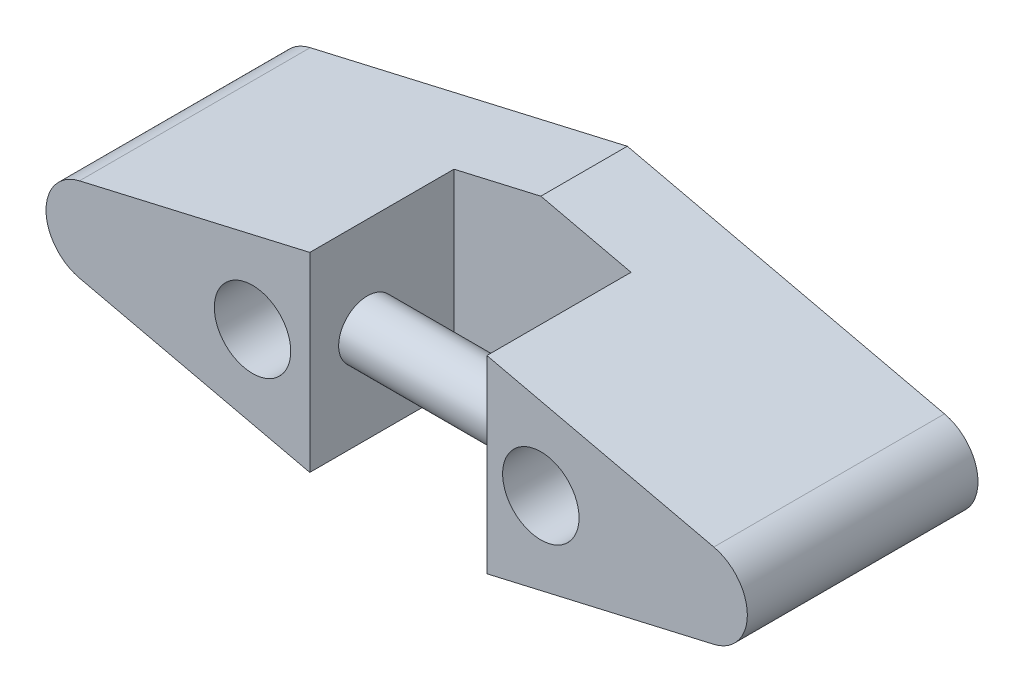
from build123d import *

# Parameters (mm, degrees)
SKETCH1_R           = 2.65
BOSS_EXTRUDE1_DEPTH = 16
SKETCH3_W           = 12.283798513
SKETCH3_H           = 21.086734885
CUT_EXTRUDE2_DEPTH  = 10
BOSS_EXTRUDE2_REACH = 32.583
SKETCH4_R           = 2


with BuildPart() as part:
    # Sketch1 → Boss-Extrude1 (new body)
    with BuildSketch(Plane.XY):
        with BuildLine():
            Line((0, 8), (-22, 2.922544759))
            ThreePointArc((-22, 2.922544759), (-24.325354345, -0.000692743), (-21.999845251, -2.923807139))
            Line((-21.999845251, -2.923807139), (0, -8))
            Line((0, -8), (21.999845251, -2.923807139))
            ThreePointArc((21.999845251, -2.923807139), (24.325354345, -0.000692743), (22, 2.922544759))
            Line((22, 2.922544759), (0, 8))
        make_face()
        with Locations((10, 0)):
            Circle(SKETCH1_R, mode=Mode.SUBTRACT)
        with Locations((-10, 0)):
            Circle(SKETCH1_R, mode=Mode.SUBTRACT)
    extrude(amount=BOSS_EXTRUDE1_DEPTH)

    # Sketch3 → Cut-Extrude2 (cut)
    with BuildSketch(Plane.XY.offset(16)):
        with Locations((0.115880044, 2.543367443)):
            Rectangle(SKETCH3_W, SKETCH3_H)
    extrude(amount=-CUT_EXTRUDE2_DEPTH, mode=Mode.SUBTRACT)

    # Sketch4 → Boss-Extrude2 (add, up to next)
    with BuildSketch(Plane.ZY.offset(-6.257779301), mode=Mode.PRIVATE) as boss_extrude2_sk1:
        with Locations((12, 0.000745713)):
            Circle(SKETCH4_R)
    boss_extrude2_tool1 = extrude(boss_extrude2_sk1.sketch, amount=BOSS_EXTRUDE2_REACH, mode=Mode.PRIVATE) - part.part
    add(boss_extrude2_tool1.solids().sort_by_distance((6.257779, 0.000746, 12))[0])


solid = part.part
